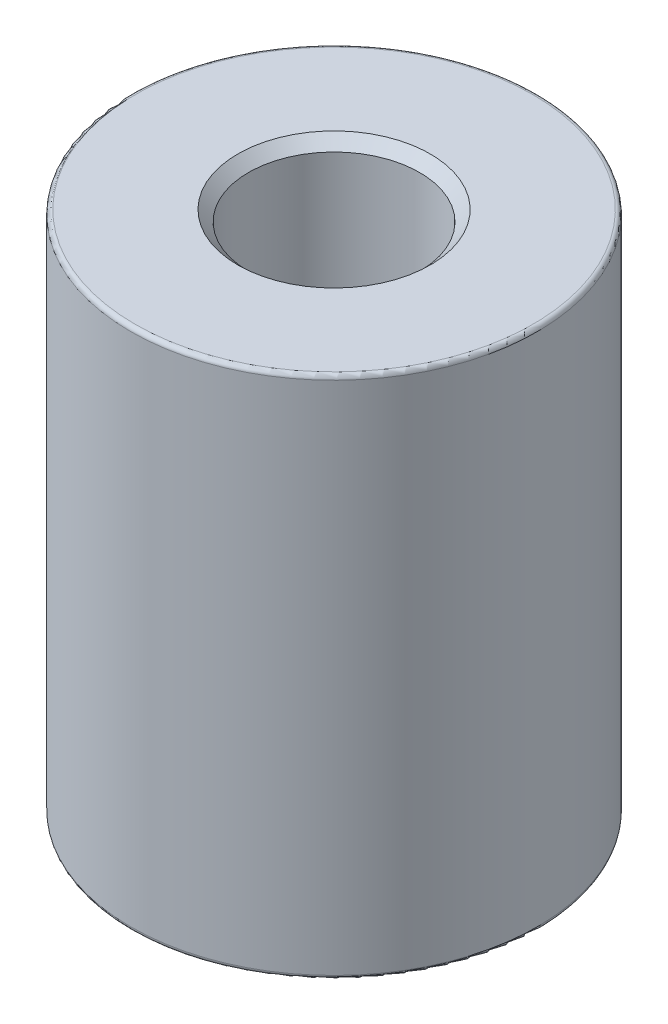
from build123d import *

# Parameters (mm, degrees)
SKETCH_1_R          = 9.5
EXTRUDE_1_DEPTH     = 24.5
SKETCH_2_R          = 4
CUT_EXTRUDE_1_DEPTH = 16
SKETCH_3_R          = 3
CUT_EXTRUDE_2_DEPTH = 16
CHAMFER_1_SIZE      = 0.5
FILLET_1_R          = 0.2


with BuildPart() as part:
    # 草图1 → 凸台-拉伸1 (new body)
    with BuildSketch(Plane(origin=(0, 0, 0), x_dir=(1, 0, 0), z_dir=(0, 1, 0))):
        Circle(SKETCH_1_R)
    extrude(amount=EXTRUDE_1_DEPTH)

    # 草图2 → 切除-拉伸1 (cut)
    with BuildSketch(Plane(origin=(0, 24.5, 0), x_dir=(1, 0, 0), z_dir=(0, 1, 0))):
        Circle(SKETCH_2_R)
    extrude(amount=-CUT_EXTRUDE_1_DEPTH, mode=Mode.SUBTRACT)

    # 草图3 → 切除-拉伸2 (cut)
    with BuildSketch(Plane.XZ):
        Circle(SKETCH_3_R)
    extrude(amount=-CUT_EXTRUDE_2_DEPTH, mode=Mode.SUBTRACT)

    # 倒角1
    chamfer_1_edges = [part.edges().sort_by_distance(p)[0] for p in [
        (-3, 0, 0),
        (-4, 24.5, 0),
    ]]
    chamfer(chamfer_1_edges, length=CHAMFER_1_SIZE)

    # 圆角1
    fillet_1_edges = [part.edges().sort_by_distance(p)[0] for p in [
        (-9.5, 0, 0),
        (-9.5, 24.5, 0),
    ]]
    fillet(fillet_1_edges, radius=FILLET_1_R)


solid = part.part
